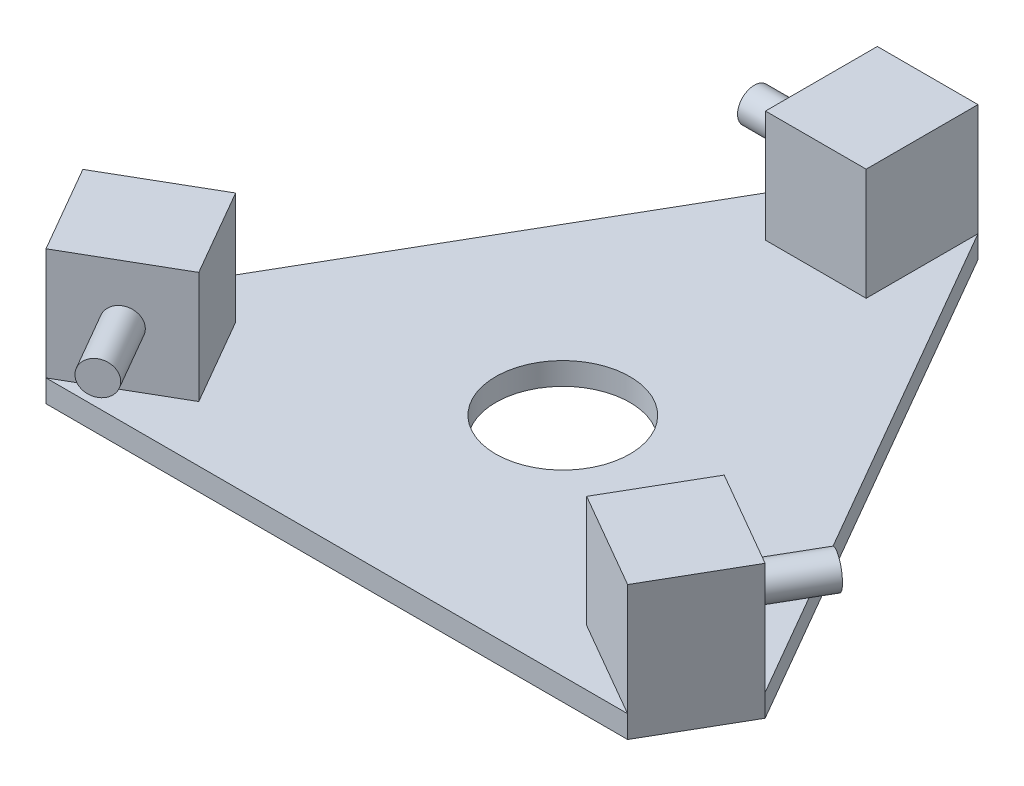
from build123d import *

# Parameters (mm, degrees)
SKETCH1_R           = 30
BOSS_EXTRUDE1_DEPTH = 10
SKETCH2_W           = 45
SKETCH2_H           = 50
BOSS_EXTRUDE2_DEPTH = 50
SKETCH3_R           = 7.5
BOSS_EXTRUDE3_DEPTH = 30
SKETCH4_R           = 7.5
BOSS_EXTRUDE4_DEPTH = 30
SKETCH5_R           = 7.5
BOSS_EXTRUDE5_DEPTH = 30


with BuildPart() as part:
    # Sketch1 → Boss-Extrude1 (new body)
    with BuildSketch(Plane(origin=(0, 0, 0), x_dir=(1, 0, 0), z_dir=(0, 1, 0))):
        Polygon((-152.5, -62.065153938), (-130, -101.036297108), (130, -101.036297108), (152.5, -62.065153938), (22.5, 163.101451046), (-22.5, 163.101451046), align=None)
        Circle(SKETCH1_R, mode=Mode.SUBTRACT)
    extrude(amount=BOSS_EXTRUDE1_DEPTH)

    # Sketch2 → Boss-Extrude2 (add)
    with BuildSketch(Plane(origin=(0, 10, 0), x_dir=(1, 0, 0), z_dir=(0, 1, 0))):
        with Locations((0, 138.101451046)):
            Rectangle(SKETCH2_W, SKETCH2_H)
        Polygon((-86.698729811, -76.036297108), (-130, -101.036297108), (-152.5, -62.065153938), (-109.198729811, -37.065153938), align=None)
        Polygon((86.698729811, -76.036297108), (130, -101.036297108), (152.5, -62.065153938), (109.198729811, -37.065153938), align=None)
    extrude(amount=BOSS_EXTRUDE2_DEPTH)

    # Sketch3 → Boss-Extrude3 (add)
    with BuildSketch(Plane(origin=(-22.5, 0, -140.601451046), x_dir=(0, 0, -1), z_dir=(1, 0, 0))):
        with Locations((-2.5, 35)):
            Circle(SKETCH3_R)
    extrude(amount=-BOSS_EXTRUDE3_DEPTH)

    # Sketch4 → Boss-Extrude4 (add)
    with BuildSketch(Plane(origin=(133.014428415, 0, 50.815153938), x_dir=(0.866025404, 0, 0.5), z_dir=(-0.5, 0, 0.866025404))):
        with Locations((-2.5, 35)):
            Circle(SKETCH4_R)
    extrude(amount=-BOSS_EXTRUDE4_DEPTH)

    # Sketch5 → Boss-Extrude5 (add)
    with BuildSketch(Plane(origin=(-110.514428415, 0, 89.786297108), x_dir=(-0.866025404, 0, 0.5), z_dir=(-0.5, 0, -0.866025404))):
        with Locations((-2.5, 35)):
            Circle(SKETCH5_R)
    extrude(amount=-BOSS_EXTRUDE5_DEPTH)


solid = part.part
